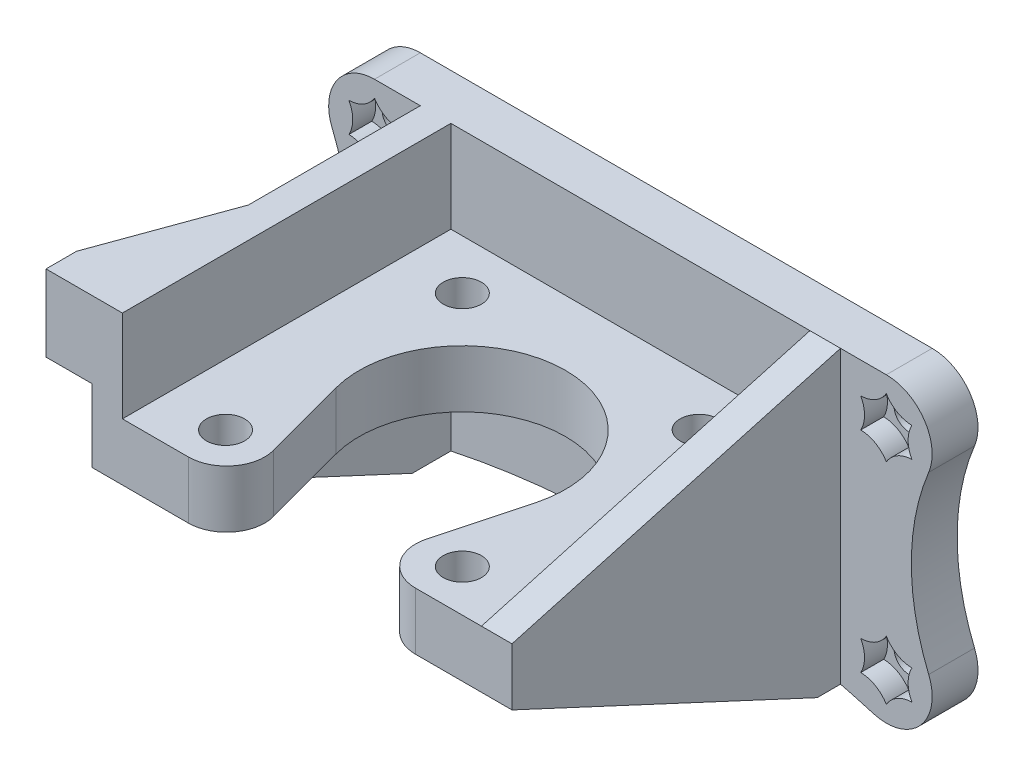
from build123d import *

# Parameters (mm, degrees)
BOSS_EXTRUDE1_DEPTH  = 49
SKETCH2_R            = 2.5
CUT_EXTRUDE1_DEPTH   = 8.5
SKETCH4_W            = 79
SKETCH4_H            = 39.5
BOSS_EXTRUDE2_DEPTH  = 6
BOSS_EXTRUDE3_DEPTH  = 4
SKETCH5_R            = 2
CUT_EXTRUDE3_DEPTH   = 10
BOSS_EXTRUDE4_DEPTH  = 4
FILLET1_R            = 6
FILLET2_R            = 5
CUT_EXTRUDE5_DEPTH   = 3
CUT_EXTRUDE6_DEPTH   = 50
CUT_EXTRUDE7_DEPTH   = 3
LPATTERN1_COUNT      = 2
LPATTERN1_PITCH      = 67
LPATTERN1_COUNT_DIR2 = 2
LPATTERN1_PITCH_DIR2 = 27.5
BOSS_EXTRUDE5_DEPTH  = 10


with BuildPart() as part:
    # Sketch1 → Boss-Extrude1 (new body)
    with BuildSketch(Plane.XY):
        Polygon((4, 7.5), (4, 19.5), (0, 19.5), (0, 0), (55, 0), (55, 7.5), align=None)
    extrude(amount=BOSS_EXTRUDE1_DEPTH)

    # Sketch2 → Cut-Extrude1 (cut, through all)
    with BuildSketch(Plane(origin=(0, 7.5, 0), x_dir=(1, 0, 0), z_dir=(0, 1, 0))):
        with Locations(Location((12, -12.5, 0), (0, 0, 270))):  # turned: the seam where the file's is
            Circle(SKETCH2_R)
        with Locations(Location((43, -12.5, 0), (0, 0, 270))):  # turned: the seam where the file's is
            Circle(SKETCH2_R)
        with Locations(Location((12, -43.5, 0), (0, 0, 270))):  # turned: the seam where the file's is
            Circle(SKETCH2_R)
        with Locations(Location((43, -43.5, 0), (0, 0, 270))):  # turned: the seam where the file's is
            Circle(SKETCH2_R)
        with BuildLine():
            Line((14.460001345, -31.494057109), (19.150704606, -49))
            Line((19.150704606, -49), (35.849295394, -49))
            Line((35.849295394, -49), (40.539998655, -31.494057109))
            ThreePointArc((40.539998655, -31.494057109), (27.5, -14.5), (14.460001345, -31.494057109))
        make_face()
    extrude(amount=-CUT_EXTRUDE1_DEPTH, mode=Mode.SUBTRACT)

    # Sketch4 → Boss-Extrude2 (add)
    with BuildSketch(Plane(origin=(0, 0, 0), x_dir=(-1, 0, 0), z_dir=(0, 0, -1))):
        with Locations((-27.5, -0.25)):
            Rectangle(SKETCH4_W, SKETCH4_H)
    extrude(amount=-BOSS_EXTRUDE2_DEPTH)

    # Sketch6 → Boss-Extrude3 (add)
    with BuildSketch(Plane.ZY):
        Polygon((6, -20), (49, 0), (6, 0), align=None)
    extrude(amount=-BOSS_EXTRUDE3_DEPTH)

    # Sketch5 → Cut-Extrude3 (cut)
    with BuildSketch(Plane(origin=(0, 0, 0), x_dir=(-1, 0, 0), z_dir=(0, 0, -1))):
        with Locations((-61, 13.5)):
            Circle(SKETCH5_R)
        with Locations((-61, -14)):
            Circle(SKETCH5_R)
        with Locations((6, 13.5)):
            Circle(SKETCH5_R)
        with Locations((6, -14)):
            Circle(SKETCH5_R)
    extrude(amount=-CUT_EXTRUDE3_DEPTH, mode=Mode.SUBTRACT)

    # Sketch7 → Boss-Extrude4 (add)
    with BuildSketch(Plane(origin=(55, 0, 0), x_dir=(0, 0, -1), z_dir=(1, 0, 0))):
        Polygon((-49, 7.5), (-6, 19.5), (0, 19.5), (0, -20), (-6, -20), (-49, 0), align=None)
    extrude(amount=-BOSS_EXTRUDE4_DEPTH)

    # Fillet1
    fillet1_edges = [part.edges().sort_by_distance(p)[0] for p in [
        (67, 19.5, 3),
        (-12, 19.5, 3),
        (-12, -20, 3),
        (67, -20, 3),
    ]]
    fillet(fillet1_edges, radius=FILLET1_R)

    # Fillet2
    fillet2_edges = [part.edges().sort_by_distance(p)[0] for p in [
        (35.849295394, 3.75, 49),
        (19.150704606, 3.75, 49),
    ]]
    fillet(fillet2_edges, radius=FILLET2_R)

    # Sketch9 → Cut-Extrude5 (cut)
    with BuildSketch(Plane.XY.offset(6)):
        Polygon((-6, 16.790896534), (-8.85, 15.145448267), (-8.85, 11.854551733), (-6, 10.209103466), (-3.15, 11.854551733), (-3.15, 15.145448267), align=None)
        Polygon((-6, -10.709103466), (-8.85, -12.354551733), (-8.85, -15.645448267), (-6, -17.290896534), (-3.15, -15.645448267), (-3.15, -12.354551733), align=None)
        Polygon((61, -10.709103466), (58.15, -12.354551733), (58.15, -15.645448267), (61, -17.290896534), (63.85, -15.645448267), (63.85, -12.354551733), align=None)
        Polygon((61, 10.209103466), (63.85, 11.854551733), (63.85, 15.145448267), (61, 16.790896534), (58.15, 15.145448267), (58.15, 11.854551733), align=None)
    extrude(amount=-CUT_EXTRUDE5_DEPTH, mode=Mode.SUBTRACT)

    # Sketch10 → Cut-Extrude6 (cut, through all)
    with BuildSketch(Plane(origin=(0, 0, 0), x_dir=(-1, 0, 0), z_dir=(0, 0, -1))):
        with BuildLine():
            Line((-61, 19.5), (-61, 26.194717678))
            Line((-61, 26.194717678), (-93.21372943, 26.194717678))
            Line((-93.21372943, 26.194717678), (-93.21372943, -32.483465835))
            Line((-93.21372943, -32.483465835), (20.656804912, -32.483465835))
            Line((20.656804912, -32.483465835), (20.656804912, 27.240467483))
            Line((20.656804912, 27.240467483), (6, 27.240467483))
            Line((6, 27.240467483), (6, 19.5))
            ThreePointArc((6, 19.5), (10.987484336, 16.835416016), (11.545111711, 11.208333333))
            ThreePointArc((11.545111711, 11.208333333), (9.270670267, -0.25), (11.545111711, -11.708333333))
            ThreePointArc((11.545111711, -11.708333333), (10.460015748, -18.013509627), (4.303797468, -19.755249514))
            ThreePointArc((4.303797468, -19.755249514), (-27.5, -15.166177907), (-59.303797468, -19.755249514))
            ThreePointArc((-59.303797468, -19.755249514), (-65.460015748, -18.013509627), (-66.545111711, -11.708333333))
            ThreePointArc((-66.545111711, -11.708333333), (-64.270670267, -0.25), (-66.545111711, 11.208333333))
            ThreePointArc((-66.545111711, 11.208333333), (-65.987484336, 16.835416016), (-61, 19.5))
        make_face()
    extrude(amount=-CUT_EXTRUDE6_DEPTH, mode=Mode.SUBTRACT)

    # Sketch11 → Cut-Extrude7 (cut)
    with BuildSketch(Plane.XY.offset(6)):
        with BuildLine():
            ThreePointArc((-9.35, 15.434123402), (-8.85, 13.5), (-9.35, 11.565876598))
            ThreePointArc((-9.35, 11.565876598), (-7.425, 11.031827599), (-6, 9.631753196))
            ThreePointArc((-6, 9.631753196), (-4.575, 11.031827599), (-2.65, 11.565876598))
            ThreePointArc((-2.65, 11.565876598), (-3.15, 13.5), (-2.65, 15.434123402))
            ThreePointArc((-2.65, 15.434123402), (-4.575, 15.968172401), (-6, 17.368246804))
            ThreePointArc((-6, 17.368246804), (-7.425, 15.968172401), (-9.35, 15.434123402))
        make_face()
    cut_extrude7 = extrude(amount=-CUT_EXTRUDE7_DEPTH, mode=Mode.SUBTRACT)

    # LPattern1: Cut-Extrude7 2 × 2
    with Locations(*[(i * LPATTERN1_PITCH, -j * LPATTERN1_PITCH_DIR2, 0) for i in range(LPATTERN1_COUNT) for j in range(LPATTERN1_COUNT_DIR2) if (i, j) != (0, 0)]):
        add(cut_extrude7, mode=Mode.SUBTRACT)

    # Sketch12 → Boss-Extrude5 (add)
    with BuildSketch(Plane(origin=(0, 19.5, 0), x_dir=(1, 0, 0), z_dir=(0, 1, 0))):
        Polygon((0, -49), (-6, -49), (-6, -45), (0, -28.515135483), align=None)
    extrude(amount=-BOSS_EXTRUDE5_DEPTH)


solid = part.part
